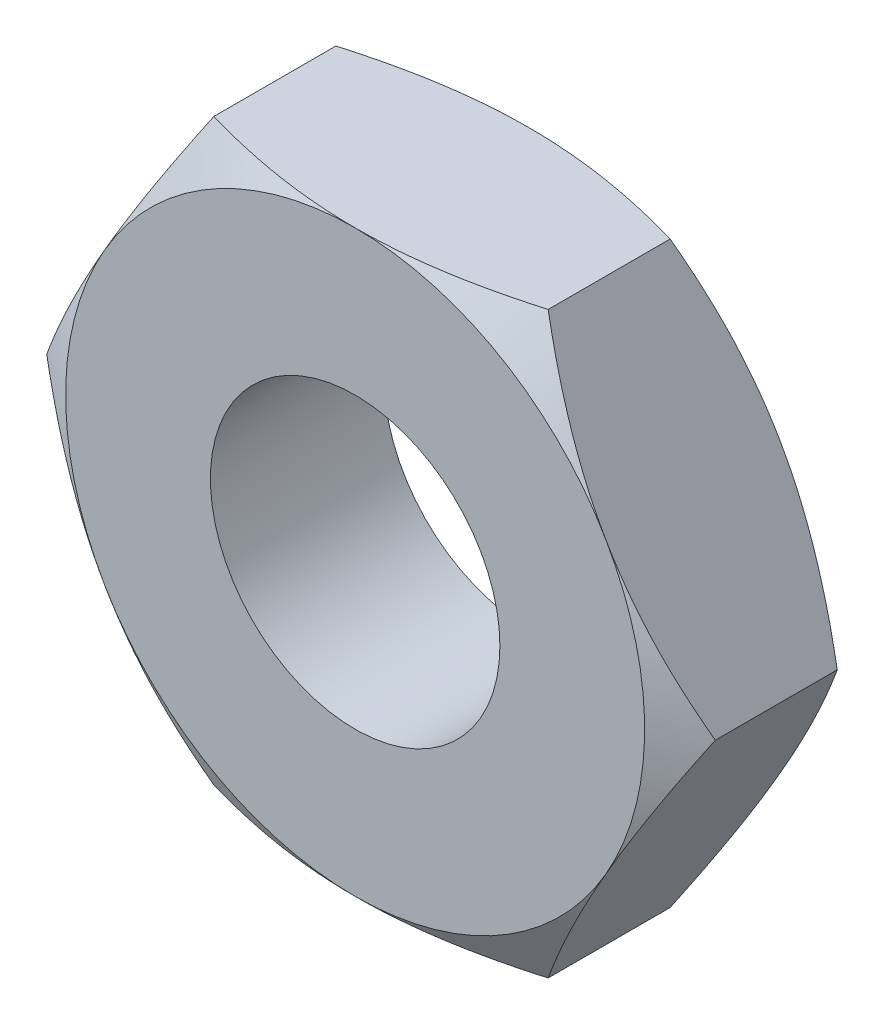
from build123d import *

# Parameters (mm, degrees)
HEX_2_DEPTH          = 1.2
THREAD_BORESKETCH4_R = 1
THREAD_BORE_DEPTH    = 2.2


with BuildPart() as part:
    # HexSketch1 → Hex 2 (new body)
    with BuildSketch(Plane.XY):
        Polygon((1.154700538, 2), (-1.154700538, 2), (-2.309401077, 0), (-1.154700538, -2), (1.154700538, -2), (2.309401077, 0), align=None)
    extrude(amount=-HEX_2_DEPTH)

    # Thread_BoreSketch4 → Thread_Bore (cut, through all)
    with BuildSketch(Plane.XY):
        Circle(THREAD_BORESKETCH4_R)
    extrude(amount=-THREAD_BORE_DEPTH, mode=Mode.SUBTRACT)

    # NUT_CHAMFERSketch10 → NUT_CHAMFER (revolve, cut)
    with BuildSketch(Plane(origin=(0, 0, 0), x_dir=(0, 0, -1), z_dir=(0.866025404, 0.5, 0))):
        Polygon((0, 2), (0.178632795, 2.309401077), (0, 2.309401077), align=None)
        Polygon((1.2, 2), (1.021367205, 2.309401077), (1.2, 2.309401077), align=None)
    revolve(axis=Axis((0, 0, 50), (0, 0, -1)), mode=Mode.SUBTRACT)


solid = part.part
